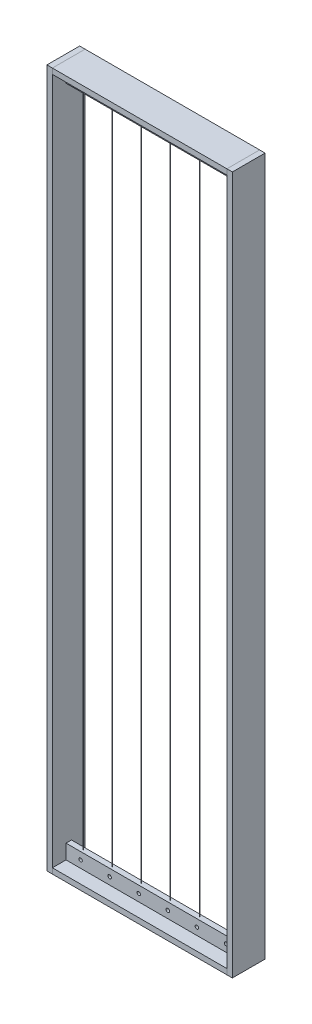
from build123d import *

# Parameters (mm, degrees)
SKETCH1_W             = 609.6
SKETCH1_H             = 114.3
BOSS_EXTRUDE1_DEPTH   = 19.05
SKETCH2_W             = 19.05
SKETCH2_H             = 114.3
BOSS_EXTRUDE2_DEPTH   = 2438.4
BOSS_EXTRUDE2_2_DEPTH = 2438.4
SKETCH3_W             = 114.3
SKETCH3_H             = 19.05
BOSS_EXTRUDE3_DEPTH   = 609.6
SKETCH4_W             = 609.6
SKETCH4_H             = 19.05
BOSS_EXTRUDE4_DEPTH   = 50.8
SKETCH5_W             = 19.05
SKETCH5_H             = 50.8
BOSS_EXTRUDE5_DEPTH   = 609.6
SKETCH7_R             = 3.175
SKETCH7_R_2           = 6.071594162
CUT_EXTRUDE1_DEPTH    = 50.8
SKETCH8_R             = 0.254
BOSS_EXTRUDE6_DEPTH   = 2298.7


with BuildPart() as part:
    # Sketch1 → Boss-Extrude1 (new body)
    with BuildSketch(Plane(origin=(0, 0, 0), x_dir=(1, 0, 0), z_dir=(0, 1, 0))):
        with Locations((-832.71662531, 42.685235732)):
            Rectangle(SKETCH1_W, SKETCH1_H)
    extrude(amount=BOSS_EXTRUDE1_DEPTH)


with BuildPart() as body_2:
    # Sketch2 → Boss-Extrude2 (new body)
    with BuildSketch(Plane(origin=(0, 0, 0), x_dir=(1, 0, 0), z_dir=(0, 1, 0))):
        with Locations((-518.39162531, 42.685235732)):
            Rectangle(SKETCH2_W, SKETCH2_H)
    extrude(amount=BOSS_EXTRUDE2_DEPTH)


with BuildPart() as body_3:
    # Sketch2 → Boss-Extrude2 2 (new body)
    with BuildSketch(Plane(origin=(0, 0, 0), x_dir=(1, 0, 0), z_dir=(0, 1, 0))):
        with Locations((-1147.04162531, 42.685235732)):
            Rectangle(SKETCH2_W, SKETCH2_H)
    extrude(amount=BOSS_EXTRUDE2_2_DEPTH)


with BuildPart() as body_4:
    # Sketch3 → Boss-Extrude3 (new body)
    with BuildSketch(Plane(origin=(-1137.51662531, 0, 0), x_dir=(0, 0, -1), z_dir=(1, 0, 0))):
        with Locations((42.685235732, 2428.875)):
            Rectangle(SKETCH3_W, SKETCH3_H)
    extrude(amount=BOSS_EXTRUDE3_DEPTH)


with BuildPart() as body_5:
    # Sketch4 → Boss-Extrude4 (new body)
    with BuildSketch(Plane(origin=(0, 19.05, 0), x_dir=(1, 0, 0), z_dir=(0, 1, 0))):
        with Locations((-832.71662531, 42.685235732)):
            Rectangle(SKETCH4_W, SKETCH4_H)
    extrude(amount=BOSS_EXTRUDE4_DEPTH)


with BuildPart() as body_6:
    # Sketch5 → Boss-Extrude5 (new body)
    with BuildSketch(Plane(origin=(-1137.51662531, 0, 0), x_dir=(0, 0, -1), z_dir=(1, 0, 0))):
        with Locations((42.685235732, 2393.95)):
            Rectangle(SKETCH5_W, SKETCH5_H)
    extrude(amount=BOSS_EXTRUDE5_DEPTH)


with BuildPart() as cut_extrude1_tool:
    # Sketch7 → Cut-Extrude1 (new body)
    with BuildSketch(Plane.XY.offset(-33.160235732)):
        with Locations((-1086.71662531, 2393.95)):
            Circle(SKETCH7_R)
        with Locations((-985.11662531, 2393.95)):
            Circle(SKETCH7_R)
        with Locations((-883.51662531, 2393.95)):
            Circle(SKETCH7_R)
        with Locations((-781.91662531, 2393.95)):
            Circle(SKETCH7_R)
        with Locations((-680.31662531, 2393.95)):
            Circle(SKETCH7_R)
        with Locations((-578.71662531, 2393.95)):
            Circle(SKETCH7_R)
        with Locations((-1086.71662531, 44.45)):
            Circle(SKETCH7_R_2)
        with Locations((-985.11662531, 44.45)):
            Circle(SKETCH7_R_2)
        with Locations((-883.51662531, 44.45)):
            Circle(SKETCH7_R_2)
        with Locations((-781.91662531, 44.45)):
            Circle(SKETCH7_R_2)
        with Locations((-680.31662531, 44.45)):
            Circle(SKETCH7_R_2)
        with Locations((-578.71662531, 44.45)):
            Circle(SKETCH7_R_2)
    extrude(amount=-CUT_EXTRUDE1_DEPTH)


with BuildPart() as body_5_1:
    add(body_5.part)

    # Cut-Extrude1: cut by cut_extrude1_tool
    add(cut_extrude1_tool.part, mode=Mode.SUBTRACT)



with BuildPart() as body_6_1:
    add(body_6.part)

    # Cut-Extrude1: cut by cut_extrude1_tool
    add(cut_extrude1_tool.part, mode=Mode.SUBTRACT)


with BuildPart() as body_5_2:
    add(body_5_1.part)

    add(body_6_1.part)  # Boss-Extrude6 merges body 6
    # Sketch8 → Boss-Extrude6 (add)
    with BuildSketch(Plane.XZ.offset(-2368.55)):
        with Locations(Location((-1086.970147606, -42.202644807, 0), (0, 0, 89.999999999))):  # turned: the seam where the file's is
            Circle(SKETCH8_R)
        with Locations(Location((-1086.487556681, -42.685235732, 0), (0, 0, 90.000000001))):  # turned: the seam where the file's is
            Circle(SKETCH8_R)
        with Locations(Location((-1086.970147606, -43.167826657, 0), (0, 0, 89.999999999))):  # turned: the seam where the file's is
            Circle(SKETCH8_R)
        with Locations(Location((-1087.452738531, -42.685235732, 0), (0, 0, 90.000000001))):  # turned: the seam where the file's is
            Circle(SKETCH8_R)
        with Locations(Location((-985.852738531, -42.685235732, 0), (0, 0, 90))):  # turned: the seam where the file's is
            Circle(SKETCH8_R)
        with Locations(Location((-985.370147606, -43.167826657, 0), (0, 0, 90))):  # turned: the seam where the file's is
            Circle(SKETCH8_R)
        with Locations(Location((-985.370147606, -42.202644807, 0), (0, 0, 90))):  # turned: the seam where the file's is
            Circle(SKETCH8_R)
        with Locations(Location((-984.887556681, -42.685235732, 0), (0, 0, 90))):  # turned: the seam where the file's is
            Circle(SKETCH8_R)
        with Locations(Location((-884.252738531, -42.685235732, 0), (0, 0, 90))):  # turned: the seam where the file's is
            Circle(SKETCH8_R)
        with Locations(Location((-883.770147606, -43.167826657, 0), (0, 0, 90))):  # turned: the seam where the file's is
            Circle(SKETCH8_R)
        with Locations(Location((-883.770147606, -42.202644807, 0), (0, 0, 90))):  # turned: the seam where the file's is
            Circle(SKETCH8_R)
        with Locations(Location((-883.287556681, -42.685235732, 0), (0, 0, 90))):  # turned: the seam where the file's is
            Circle(SKETCH8_R)
        with Locations(Location((-782.652738531, -42.685235732, 0), (0, 0, 90))):  # turned: the seam where the file's is
            Circle(SKETCH8_R)
        with Locations(Location((-782.170147606, -43.167826657, 0), (0, 0, 90))):  # turned: the seam where the file's is
            Circle(SKETCH8_R)
        with Locations(Location((-782.170147606, -42.202644807, 0), (0, 0, 90))):  # turned: the seam where the file's is
            Circle(SKETCH8_R)
        with Locations(Location((-781.687556681, -42.685235732, 0), (0, 0, 90))):  # turned: the seam where the file's is
            Circle(SKETCH8_R)
        with Locations(Location((-681.052738531, -42.685235732, 0), (0, 0, 90))):  # turned: the seam where the file's is
            Circle(SKETCH8_R)
        with Locations(Location((-680.570147606, -43.167826657, 0), (0, 0, 90))):  # turned: the seam where the file's is
            Circle(SKETCH8_R)
        with Locations(Location((-680.570147606, -42.202644807, 0), (0, 0, 90))):  # turned: the seam where the file's is
            Circle(SKETCH8_R)
        with Locations(Location((-680.087556681, -42.685235732, 0), (0, 0, 90))):  # turned: the seam where the file's is
            Circle(SKETCH8_R)
        with Locations(Location((-579.452738531, -42.685235732, 0), (0, 0, 90))):  # turned: the seam where the file's is
            Circle(SKETCH8_R)
        with Locations(Location((-578.970147606, -43.167826657, 0), (0, 0, 90))):  # turned: the seam where the file's is
            Circle(SKETCH8_R)
        with Locations(Location((-578.970147606, -42.202644807, 0), (0, 0, 90))):  # turned: the seam where the file's is
            Circle(SKETCH8_R)
        with Locations(Location((-578.487556681, -42.685235732, 0), (0, 0, 90))):  # turned: the seam where the file's is
            Circle(SKETCH8_R)
    extrude(amount=BOSS_EXTRUDE6_DEPTH)


solid = Compound([part.part, body_2.part, body_3.part, body_4.part, body_5_2.part])
